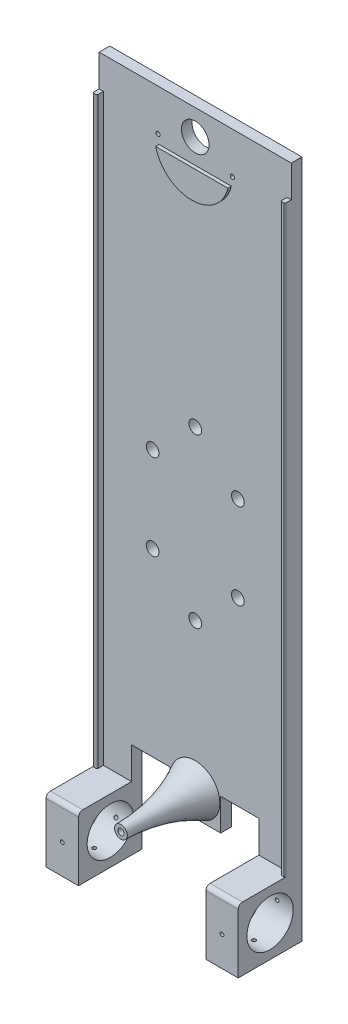
from build123d import *

# Parameters (mm, degrees)
SKETCH1_W                    = 320
SKETCH1_H                    = 90.51
CHASSIS_BASE_DEPTH           = 5
SKETCH3_W                    = 2
SKETCH3_H                    = 275
LATERAL_GUARD_DEPTH          = 3
DRIVE_ATTACHMENT_POINT_REACH = 10
SKETCH4_R                    = 3
CUT_EXTRUDE2_REACH           = 7
SKETCH5_R                    = 6.5
SKETCH5_R_2                  = 1
SKETCH6_W                    = 30
SKETCH6_H                    = 30
BOSS_EXTRUDE1_DEPTH          = 90.51
CUT_EXTRUDE3_REACH           = 32
SKETCH7_W                    = 60
SKETCH7_H                    = 30
FILLET3_R                    = 0.5
FILLET4_R                    = 2
SKETCH9_R                    = 0.875
CUT_EXTRUDE5_DEPTH           = 5
SKETCH10_R                   = 0.875
CUT_EXTRUDE6_DEPTH           = 5
SKETCH11_R                   = 0.875
CUT_EXTRUDE7_DEPTH           = 5
SKETCH12_R                   = 0.875
CUT_EXTRUDE8_DEPTH           = 5
SKETCH13_R                   = 0.875
CUT_EXTRUDE9_DEPTH           = 5
SKETCH14_R                   = 0.875
CUT_EXTRUDE10_DEPTH          = 5
BOSS_EXTRUDE2_DEPTH          = 1.6
SKETCH17_R                   = 10.925
CUT_EXTRUDE12_DEPTH          = 91.51
SKETCH18_W                   = 18
SKETCH18_H                   = 15
CUT_EXTRUDE13_DEPTH          = 6.0000001
SKETCH23_R                   = 1.5
CUT_EXTRUDE18_DEPTH          = 35


with BuildPart() as part:
    # Sketch1 → Chassis Base (new body)
    with BuildSketch(Plane(origin=(0, 0, 0), x_dir=(0, 1, 0), z_dir=(0, 0, 1))):
        Rectangle(SKETCH1_W, SKETCH1_H)
    extrude(amount=CHASSIS_BASE_DEPTH)

    # Sketch3 → Lateral Guard (add)
    with BuildSketch(Plane.XY.offset(5)):
        with Locations((-44.255, 7.5)):
            Rectangle(SKETCH3_W, SKETCH3_H)
        with Locations((44.255, 7.5)):
            Rectangle(SKETCH3_W, SKETCH3_H)
    extrude(amount=LATERAL_GUARD_DEPTH)

    # Sketch4 → Drive Attachment Point (cut, up to next)
    with BuildSketch(Plane(origin=(0, 0, 0), x_dir=(1, 0, 0), z_dir=(0, 0, -1)), mode=Mode.PRIVATE) as drive_attachment_point_sk1:
        with Locations((0, -29.7)):
            Circle(SKETCH4_R)
    drive_attachment_point_tool1 = extrude(drive_attachment_point_sk1.sketch, amount=-DRIVE_ATTACHMENT_POINT_REACH, mode=Mode.PRIVATE) & part.part
    add(drive_attachment_point_tool1.solids().sort_by_distance((0, 29.7, 0))[0], mode=Mode.SUBTRACT)
    # Sketch4 → Drive Attachment Point (cut, up to next)
    with BuildSketch(Plane(origin=(0, 0, 0), x_dir=(1, 0, 0), z_dir=(0, 0, -1)), mode=Mode.PRIVATE) as drive_attachment_point_sk2:
        with Locations((-20.08, 30)):
            Circle(SKETCH4_R)
    drive_attachment_point_tool2 = extrude(drive_attachment_point_sk2.sketch, amount=-DRIVE_ATTACHMENT_POINT_REACH, mode=Mode.PRIVATE) & part.part
    add(drive_attachment_point_tool2.solids().sort_by_distance((-20.08, -30, 0))[0], mode=Mode.SUBTRACT)
    # Sketch4 → Drive Attachment Point (cut, up to next)
    with BuildSketch(Plane(origin=(0, 0, 0), x_dir=(1, 0, 0), z_dir=(0, 0, -1)), mode=Mode.PRIVATE) as drive_attachment_point_sk3:
        with Locations((20.08, 30)):
            Circle(SKETCH4_R)
    drive_attachment_point_tool3 = extrude(drive_attachment_point_sk3.sketch, amount=-DRIVE_ATTACHMENT_POINT_REACH, mode=Mode.PRIVATE) & part.part
    add(drive_attachment_point_tool3.solids().sort_by_distance((20.08, -30, 0))[0], mode=Mode.SUBTRACT)
    # Sketch4 → Drive Attachment Point (cut, up to next)
    with BuildSketch(Plane(origin=(0, 0, 0), x_dir=(1, 0, 0), z_dir=(0, 0, -1)), mode=Mode.PRIVATE) as drive_attachment_point_sk4:
        with Locations((0, 49.3)):
            Circle(SKETCH4_R)
    drive_attachment_point_tool4 = extrude(drive_attachment_point_sk4.sketch, amount=-DRIVE_ATTACHMENT_POINT_REACH, mode=Mode.PRIVATE) & part.part
    add(drive_attachment_point_tool4.solids().sort_by_distance((0, -49.3, 0))[0], mode=Mode.SUBTRACT)
    # Sketch4 → Drive Attachment Point (cut, up to next)
    with BuildSketch(Plane(origin=(0, 0, 0), x_dir=(1, 0, 0), z_dir=(0, 0, -1)), mode=Mode.PRIVATE) as drive_attachment_point_sk5:
        with Locations((-20.08, -10.4)):
            Circle(SKETCH4_R)
    drive_attachment_point_tool5 = extrude(drive_attachment_point_sk5.sketch, amount=-DRIVE_ATTACHMENT_POINT_REACH, mode=Mode.PRIVATE) & part.part
    add(drive_attachment_point_tool5.solids().sort_by_distance((-20.08, 10.4, 0))[0], mode=Mode.SUBTRACT)
    # Sketch4 → Drive Attachment Point (cut, up to next)
    with BuildSketch(Plane(origin=(0, 0, 0), x_dir=(1, 0, 0), z_dir=(0, 0, -1)), mode=Mode.PRIVATE) as drive_attachment_point_sk6:
        with Locations((20.08, -10.4)):
            Circle(SKETCH4_R)
    drive_attachment_point_tool6 = extrude(drive_attachment_point_sk6.sketch, amount=-DRIVE_ATTACHMENT_POINT_REACH, mode=Mode.PRIVATE) & part.part
    add(drive_attachment_point_tool6.solids().sort_by_distance((20.08, 10.4, 0))[0], mode=Mode.SUBTRACT)

    # Sketch5 → Cut-Extrude2 (cut, up to next)
    with BuildSketch(Plane.XY.offset(5), mode=Mode.PRIVATE) as cut_extrude2_sk1:
        with Locations((0, 148)):
            Circle(SKETCH5_R)
    cut_extrude2_tool1 = extrude(cut_extrude2_sk1.sketch, amount=-CUT_EXTRUDE2_REACH, mode=Mode.PRIVATE) & part.part
    add(cut_extrude2_tool1.solids().sort_by_distance((0, 148, 5))[0], mode=Mode.SUBTRACT)
    # Sketch5 → Cut-Extrude2 (cut, up to next)
    with BuildSketch(Plane.XY.offset(5), mode=Mode.PRIVATE) as cut_extrude2_sk2:
        with Locations((-17.5, 140.5)):
            Circle(SKETCH5_R_2)
    cut_extrude2_tool2 = extrude(cut_extrude2_sk2.sketch, amount=-CUT_EXTRUDE2_REACH, mode=Mode.PRIVATE) & part.part
    add(cut_extrude2_tool2.solids().sort_by_distance((-17.5, 140.5, 5))[0], mode=Mode.SUBTRACT)
    # Sketch5 → Cut-Extrude2 (cut, up to next)
    with BuildSketch(Plane.XY.offset(5), mode=Mode.PRIVATE) as cut_extrude2_sk3:
        with Locations((17.5, 140.5)):
            Circle(SKETCH5_R_2)
    cut_extrude2_tool3 = extrude(cut_extrude2_sk3.sketch, amount=-CUT_EXTRUDE2_REACH, mode=Mode.PRIVATE) & part.part
    add(cut_extrude2_tool3.solids().sort_by_distance((17.5, 140.5, 5))[0], mode=Mode.SUBTRACT)

    # Sketch6 → Boss-Extrude1 (add)
    with BuildSketch(Plane.YZ.offset(45.255)):
        with Locations((-145, 15)):
            Rectangle(SKETCH6_W, SKETCH6_H)
    extrude(amount=-BOSS_EXTRUDE1_DEPTH)

    # Sketch7 → Cut-Extrude3 (cut, up to next)
    with BuildSketch(Plane.XY.offset(30), mode=Mode.PRIVATE) as cut_extrude3_sk1:
        with Locations((0, -145)):
            Rectangle(SKETCH7_W, SKETCH7_H)
    cut_extrude3_tool1 = extrude(cut_extrude3_sk1.sketch, amount=-CUT_EXTRUDE3_REACH, mode=Mode.PRIVATE) & part.part
    add(cut_extrude3_tool1.solids().sort_by_distance((0, -145, 30))[0], mode=Mode.SUBTRACT)

    # Fillet3
    fillet3_edges = [part.edges().sort_by_distance(p)[0] for p in [
        (-45.255, 7.5, 8),
        (-43.255, 7.5, 8),
        (45.255, 7.5, 8),
        (43.255, 7.5, 8),
    ]]
    fillet(fillet3_edges, radius=FILLET3_R)

    # Fillet4
    fillet4_edges = [part.edges().sort_by_distance(p)[0] for p in [
        (37.6275, -130, 30),
        (-37.6275, -130, 30),
    ]]
    fillet(fillet4_edges, radius=FILLET4_R)

    # Sketch9 → Cut-Extrude5 (cut)
    with BuildSketch(Plane.XY.offset(30)):
        with Locations((-37.6275, -146)):
            Circle(SKETCH9_R)
    extrude(amount=-CUT_EXTRUDE5_DEPTH, mode=Mode.SUBTRACT)

    # Sketch10 → Cut-Extrude6 (cut)
    with BuildSketch(Plane.XZ.offset(160)):
        with Locations((-37.6275, 15)):
            Circle(SKETCH10_R)
    extrude(amount=-CUT_EXTRUDE6_DEPTH, mode=Mode.SUBTRACT)

    # Sketch11 → Cut-Extrude7 (cut)
    with BuildSketch(Plane(origin=(0, 0, 0), x_dir=(1, 0, 0), z_dir=(0, 0, -1))):
        with Locations((-37.6275, 148.599605515)):
            Circle(SKETCH11_R)
    extrude(amount=-CUT_EXTRUDE7_DEPTH, mode=Mode.SUBTRACT)

    # Sketch12 → Cut-Extrude8 (cut)
    with BuildSketch(Plane(origin=(0, 0, 0), x_dir=(1, 0, 0), z_dir=(0, 0, -1))):
        with Locations((37.6275, 145)):
            Circle(SKETCH12_R)
    extrude(amount=-CUT_EXTRUDE8_DEPTH, mode=Mode.SUBTRACT)

    # Sketch13 → Cut-Extrude9 (cut)
    with BuildSketch(Plane.XZ.offset(160)):
        with Locations((37.6275, 15)):
            Circle(SKETCH13_R)
    extrude(amount=-CUT_EXTRUDE9_DEPTH, mode=Mode.SUBTRACT)

    # Sketch14 → Cut-Extrude10 (cut)
    with BuildSketch(Plane.XY.offset(30)):
        with Locations((37.6275, -146)):
            Circle(SKETCH14_R)
    extrude(amount=-CUT_EXTRUDE10_DEPTH, mode=Mode.SUBTRACT)

    # Sketch15 → Boss-Extrude2 (add)
    with BuildSketch(Plane.XY.offset(5)):
        with BuildLine():
            Line((-17.021586315, 136.436061109), (17.021586315, 136.436061109))
            ThreePointArc((17.021586315, 136.436061109), (0, 123), (-17.021586315, 136.436061109))
        make_face()
    extrude(amount=BOSS_EXTRUDE2_DEPTH)

    # Sketch17 → Cut-Extrude12 (cut, through all)
    with BuildSketch(Plane(origin=(-45.255, 0, 0), x_dir=(0, -1, 0), z_dir=(-1, 0, 0))):
        with Locations((145, 15)):
            Circle(SKETCH17_R)
    extrude(amount=-CUT_EXTRUDE12_DEPTH, mode=Mode.SUBTRACT)

    # Sketch18 → Cut-Extrude13 (cut, through all)
    with BuildSketch(Plane.XY.offset(5)):
        with Locations((21, -122.5)):
            Rectangle(SKETCH18_W, SKETCH18_H)
        with Locations((-21, -122.5)):
            Rectangle(SKETCH18_W, SKETCH18_H)
    extrude(amount=-CUT_EXTRUDE13_DEPTH, mode=Mode.SUBTRACT)

    # Sketch21 → Revolve1 (revolve)
    with BuildSketch(Plane.YZ):
        with BuildLine():
            Line((-118, 40), (-118, 5))
            Line((-118, 5), (-106.234133627, 4.682586024))
            add(Edge.make_bspline(
                [(-115, 40), (-114.798550354, 20.795762888), (-106.234133627, 4.682586024)],
                knots=[0, 0, 0, 1, 1, 1], degree=2))
            Line((-115, 40), (-118, 40))
        make_face()
    revolve(axis=Axis((0, -118, 40), (0, 0, -1)))

    # Sketch23 → Cut-Extrude18 (cut)
    with BuildSketch(Plane(origin=(0, 0, 40), x_dir=(0, 1, 0), z_dir=(0, 0, 1))):
        with Locations((-118, 0)):
            Circle(SKETCH23_R)
    extrude(amount=-CUT_EXTRUDE18_DEPTH, mode=Mode.SUBTRACT)


solid = part.part
